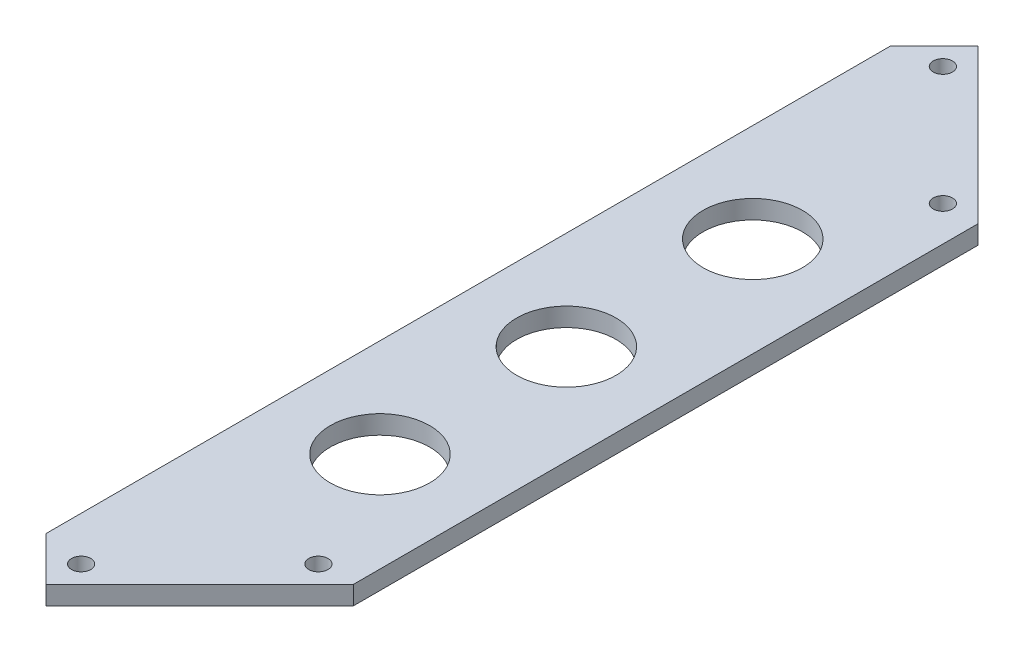
from build123d import *

# Parameters (mm, degrees)
SKETCH1_W           = 150
SKETCH1_H           = 150
BOSS_EXTRUDE1_DEPTH = 1.5
CUT_EXTRUDE1_DEPTH  = 3
SKETCH3_R           = 1.55
CUT_EXTRUDE2_DEPTH  = 3
CUT_EXTRUDE3_DEPTH  = 3
SKETCH5_R           = 8
CUT_EXTRUDE4_DEPTH  = 3


with BuildPart() as part:
    # Sketch1 → Boss-Extrude1 (new body, symmetric)
    with BuildSketch(Plane(origin=(0, 0, 0), x_dir=(1, 0, 0), z_dir=(0, 1, 0))):
        Rectangle(SKETCH1_W, SKETCH1_H)
    extrude(amount=BOSS_EXTRUDE1_DEPTH, both=True)

    # Sketch2 → Cut-Extrude1 (cut)
    with BuildSketch(Plane(origin=(0, 1.5, 0), x_dir=(1, 0, 0), z_dir=(0, 1, 0))):
        Polygon((50.251262658, 75), (75, 75), (75, 50.251262658), align=None)
        Polygon((-75, 75), (-75, 50.251262658), (-50.251262658, 75), align=None)
        Polygon((-50.251262658, -75), (-75, -75), (-75, -50.251262658), align=None)
        Polygon((75, -75), (75, -50.251262658), (50.251262658, -75), align=None)
    extrude(amount=-CUT_EXTRUDE1_DEPTH, mode=Mode.SUBTRACT)

    # Sketch3 → Cut-Extrude2 (cut)
    with BuildSketch(Plane(origin=(0, 1.5, 0), x_dir=(1, 0, 0), z_dir=(0, 1, 0))):
        with Locations((69.343145751, 50.251262658)):
            Circle(SKETCH3_R)
        with Locations((50.251262658, 69.343145751)):
            Circle(SKETCH3_R)
        with Locations((-69.343145751, 50.251262658)):
            Circle(SKETCH3_R)
        with Locations((-50.251262658, 69.343145751)):
            Circle(SKETCH3_R)
        with Locations((-69.343145751, -50.251262658)):
            Circle(SKETCH3_R)
        with Locations((-50.251262658, -69.343145751)):
            Circle(SKETCH3_R)
        with Locations((69.343145751, -50.251262658)):
            Circle(SKETCH3_R)
        with Locations((50.251262658, -69.343145751)):
            Circle(SKETCH3_R)
    extrude(amount=-CUT_EXTRUDE2_DEPTH, mode=Mode.SUBTRACT)

    # Sketch4 → Cut-Extrude3 (cut)
    with BuildSketch(Plane(origin=(0, 1.5, 0), x_dir=(1, 0, 0), z_dir=(0, 1, 0))):
        Polygon((50.251262658, 75), (-50.251262658, 75), (-75, 50.251262658), (-75, -50.251262658), (-50.251262658, -75), (50.251262658, -75), (43.180194847, -67.928932188), (43.180194847, 67.928932188), align=None)
    extrude(amount=-CUT_EXTRUDE3_DEPTH, mode=Mode.SUBTRACT)

    # Sketch5 → Cut-Extrude4 (cut)
    with BuildSketch(Plane(origin=(0, 1.5, 0), x_dir=(1, 0, 0), z_dir=(0, 1, 0))):
        with Locations((59, 0)):
            Circle(SKETCH5_R)
        with Locations((59, 30)):
            Circle(SKETCH5_R)
        with Locations((59, -30)):
            Circle(SKETCH5_R)
    extrude(amount=-CUT_EXTRUDE4_DEPTH, mode=Mode.SUBTRACT)


solid = part.part
